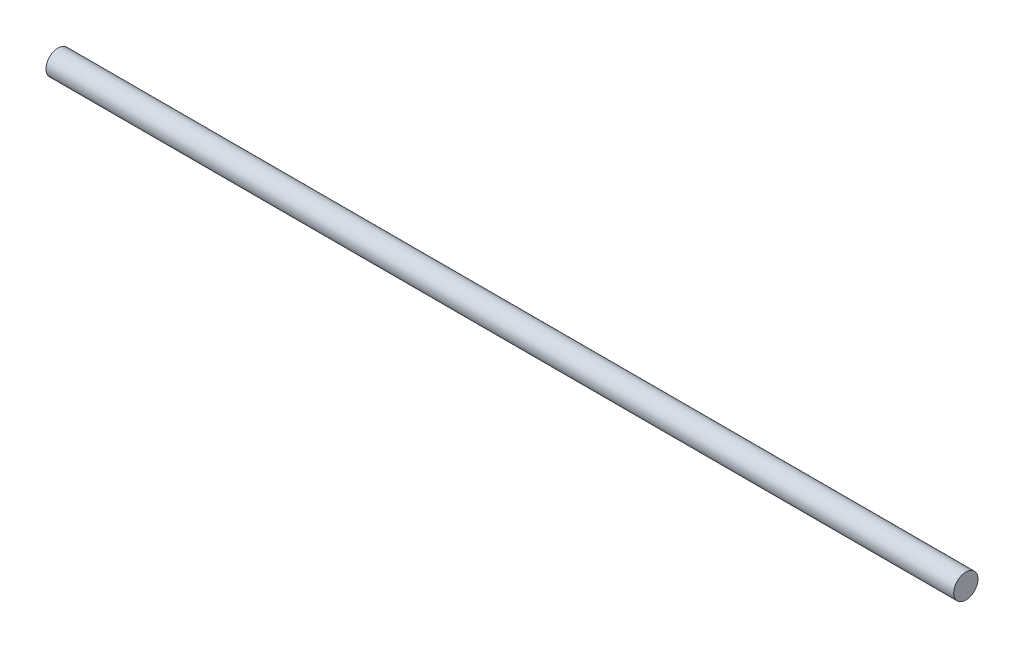
from build123d import *

# Parameters (mm, degrees)
SKETCH1_R           = 4.7625
BOSS_EXTRUDE1_DEPTH = 355.6


with BuildPart() as part:
    # Sketch1 → Boss-Extrude1 (new body)
    with BuildSketch(Plane(origin=(0, 0, 0), x_dir=(0, 0, -1), z_dir=(1, 0, 0))):
        Circle(SKETCH1_R)
    extrude(amount=BOSS_EXTRUDE1_DEPTH)


solid = part.part
